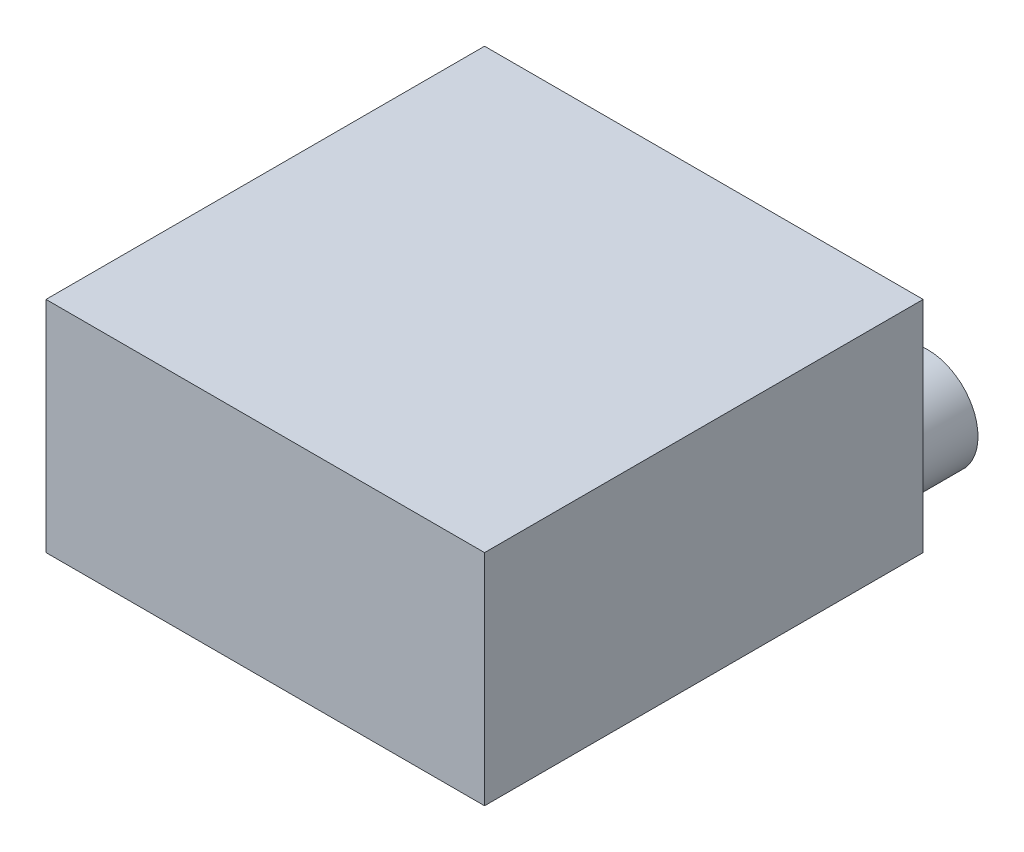
from build123d import *

# Parameters (mm, degrees)
SKETCH1_W           = 10
SKETCH1_H           = 10
BOSS_EXTRUDE1_DEPTH = 5
SKETCH2_R           = 1.143445087
BOSS_EXTRUDE2_DEPTH = 1.5


with BuildPart() as part:
    # Sketch1 → Boss-Extrude1 (new body)
    with BuildSketch(Plane(origin=(0, 0, 0), x_dir=(1, 0, 0), z_dir=(0, 1, 0))):
        with Locations((0.301507538, -4.346733668)):
            Rectangle(SKETCH1_W, SKETCH1_H)
    extrude(amount=BOSS_EXTRUDE1_DEPTH)

    # Sketch2 → Boss-Extrude2 (add)
    with BuildSketch(Plane(origin=(0, 0, -0.653266332), x_dir=(-1, 0, 0), z_dir=(0, 0, -1))):
        with Locations((-3.909378049, 1.416407491)):
            Circle(SKETCH2_R)
    extrude(amount=BOSS_EXTRUDE2_DEPTH)


solid = part.part
